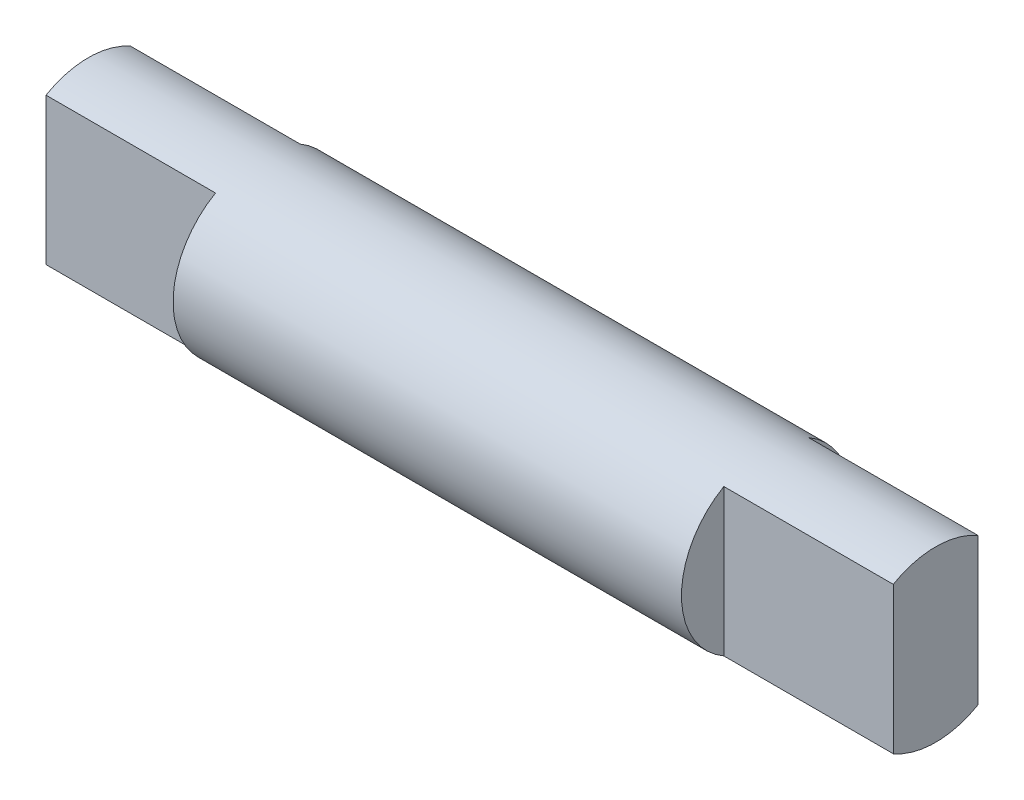
from build123d import *

# Parameters (mm, degrees)
SKETCH1_R                = 5
BOSS_EXTRUDE1_DEPTH      = 5
BOSS_EXTRUDE1_DEPTH_BACK = 45
SKETCH2_W                = 10
SKETCH2_H                = 2.5
CUT_EXTRUDE1_DEPTH       = 6
CUT_EXTRUDE1_DEPTH_BACK  = 6


with BuildPart() as part:
    # Sketch1 → Boss-Extrude1 (new body, two sides)
    with BuildSketch(Plane(origin=(0, 0, 0), x_dir=(0, 0, -1), z_dir=(1, 0, 0))) as boss_extrude1_sk:
        Circle(SKETCH1_R)
    extrude(amount=BOSS_EXTRUDE1_DEPTH)
    extrude(boss_extrude1_sk.sketch, amount=-BOSS_EXTRUDE1_DEPTH_BACK)

    # Sketch2 → Cut-Extrude1 (cut, two sides)
    with BuildSketch(Plane(origin=(0, 0, 0), x_dir=(1, 0, 0), z_dir=(0, 1, 0))) as cut_extrude1_sk:
        with Locations((-40, -3.75)):
            Rectangle(SKETCH2_W, SKETCH2_H)
        with Locations((-40, 3.75)):
            Rectangle(SKETCH2_W, SKETCH2_H)
        with Locations((0, -3.75)):
            Rectangle(SKETCH2_W, SKETCH2_H)
        with Locations((0, 3.75)):
            Rectangle(SKETCH2_W, SKETCH2_H)
    extrude(amount=CUT_EXTRUDE1_DEPTH, mode=Mode.SUBTRACT)
    extrude(cut_extrude1_sk.sketch, amount=-CUT_EXTRUDE1_DEPTH_BACK, mode=Mode.SUBTRACT)


solid = part.part
